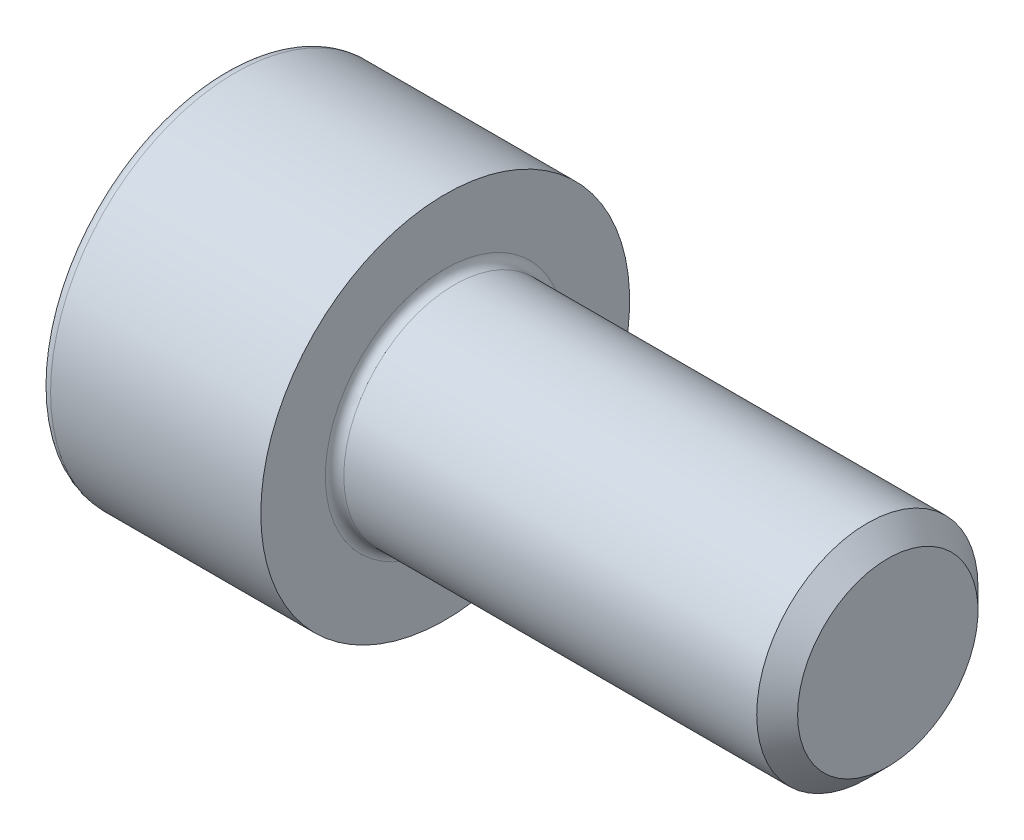
from build123d import *

# Parameters (mm, degrees)
FILLET1_R   = 0.25
FILLET2_R   = 0.3
HEX_2_DEPTH = 3


with BuildPart() as part:
    # BodySke → Base-Revolve (revolve)
    with BuildSketch(Plane.XY):
        Polygon((0, 0), (0, 5), (6, 5), (6, 3), (17.4455, 3), (18, 2.4455), (18, 0), align=None)
    revolve(axis=Axis((-31.75, 0, 0), (1, 0, 0)))

    # Fillet1
    fillet1_edges = [part.edges().sort_by_distance(p)[0] for p in [
        (6, -3, 0),
    ]]
    fillet(fillet1_edges, radius=FILLET1_R)

    # Fillet2
    fillet2_edges = [part.edges().sort_by_distance(p)[0] for p in [
        (0, -5, 0),
    ]]
    fillet(fillet2_edges, radius=FILLET2_R)

    # Sketch2 → Hex-PreBroach (revolve, cut)
    with BuildSketch(Plane.XY):
        Polygon((0, 2.542), (3, 2.542), (4.467624384, 0), (0, 0), align=None)
    revolve(axis=Axis((0, 0, 0), (1, 0, 0)), mode=Mode.SUBTRACT)

    # Sketch3 → Hex 2 (cut)
    with BuildSketch(Plane(origin=(0, 0, 0), x_dir=(0, 0.5, 0.866025404), z_dir=(-1, 0, 0))):
        Polygon((1.467624384, 2.542), (-1.467624384, 2.542), (-2.935248769, 0), (-1.467624384, -2.542), (1.467624384, -2.542), (2.935248769, 0), align=None)
    extrude(amount=-HEX_2_DEPTH, mode=Mode.SUBTRACT)


solid = part.part
